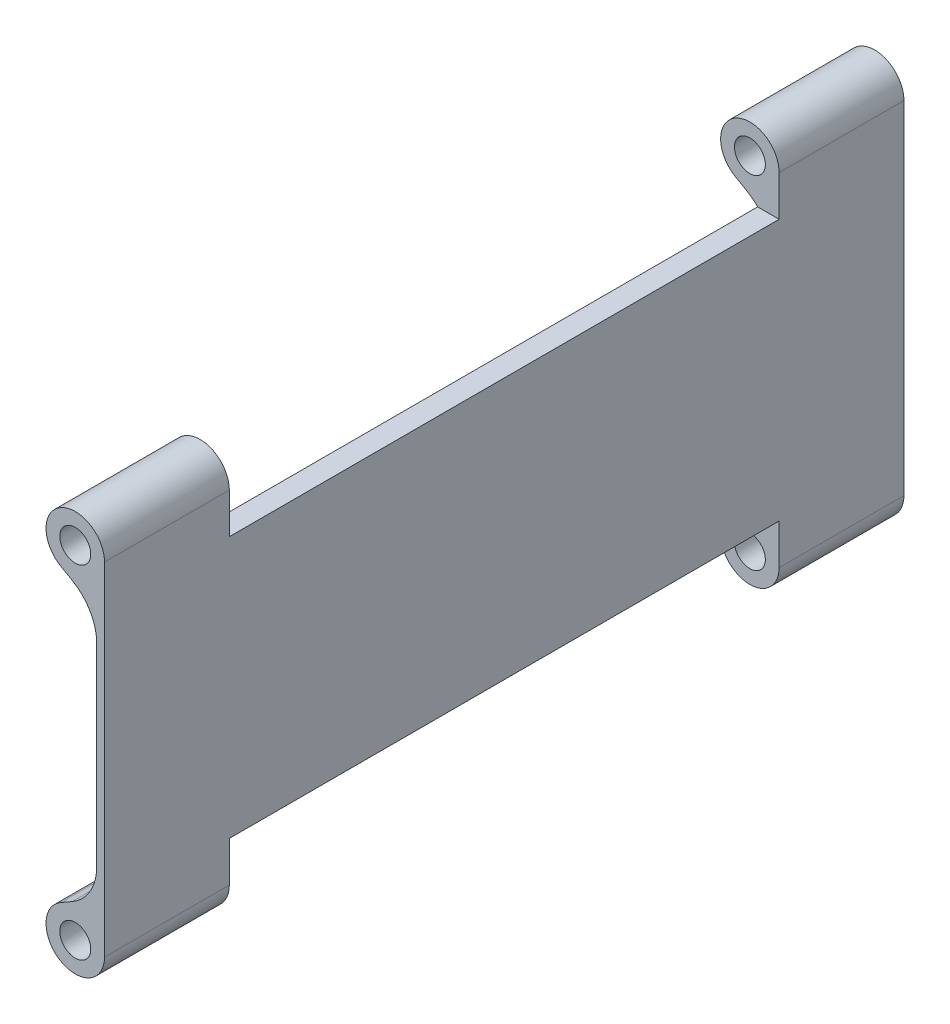
from build123d import *

# Parameters (mm, degrees)
CROQUIS1_R              = 3.175
SALIENTE_EXTRUIR1_DEPTH = 164
REDONDEO1_R             = 10
CROQUIS3_W              = 112.791812306
CROQUIS3_H              = 18.145434914
CORTAR_EXTRUIR2_DEPTH   = 13


with BuildPart() as part:
    # Croquis1 → Saliente-Extruir1 (new body)
    with BuildSketch(Plane.XY):
        with BuildLine():
            Line((-1.6, 25.646228096), (-8.98691391, 29.886314259))
            ThreePointArc((-8.98691391, 29.886314259), (-9.006535925, 40.28237342), (0, 35.09))
            Line((0, 35.09), (0, -35.09))
            ThreePointArc((0, -35.09), (-9.006535925, -40.28237342), (-8.98691391, -29.886314259))
            Line((-8.98691391, -29.886314259), (-1.6, -25.646228096))
            Line((-1.6, -25.646228096), (-1.6, 25.646228096))
        make_face()
        with Locations((-6, 35.09)):
            Circle(CROQUIS1_R, mode=Mode.SUBTRACT)
        with Locations((-6, -35.09)):
            Circle(CROQUIS1_R, mode=Mode.SUBTRACT)
    extrude(amount=-SALIENTE_EXTRUIR1_DEPTH)

    # Redondeo1
    redondeo1_edges = [part.edges().sort_by_distance(p)[0] for p in [
        (-1.6, -25.646228096, -82),
        (-1.6, 25.646228096, -82),
    ]]
    fillet(redondeo1_edges, radius=REDONDEO1_R)

    # Croquis3 → Cortar-Extruir2 (cut, through all)
    with BuildSketch(Plane(origin=(0, 0, 0), x_dir=(0, 0, -1), z_dir=(1, 0, 0))):
        with Locations((82, 35.875128035)):
            Rectangle(CROQUIS3_W, CROQUIS3_H)
        with Locations((82, -35.875128035)):
            Rectangle(CROQUIS3_W, CROQUIS3_H)
    extrude(amount=-CORTAR_EXTRUIR2_DEPTH, mode=Mode.SUBTRACT)


solid = part.part
